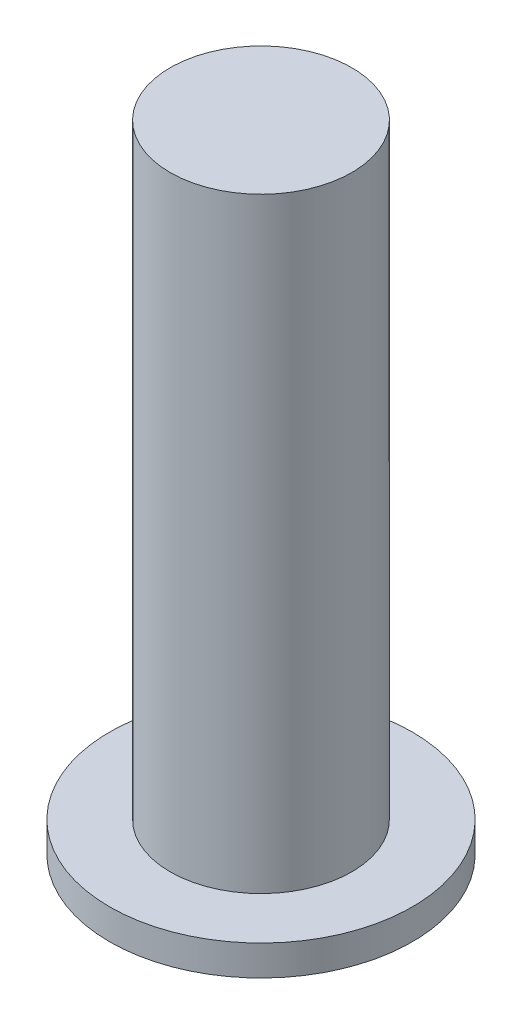
from build123d import *

# Parameters (mm, degrees)
SKETCH1_R           = 50
BOSS_EXTRUDE1_DEPTH = 10
SKETCH2_R           = 30
BOSS_EXTRUDE2_DEPTH = 200


with BuildPart() as part:
    # Sketch1 → Boss-Extrude1 (new body)
    with BuildSketch(Plane(origin=(0, 0, 0), x_dir=(1, 0, 0), z_dir=(0, 1, 0))):
        Circle(SKETCH1_R)
    extrude(amount=BOSS_EXTRUDE1_DEPTH)

    # Sketch2 → Boss-Extrude2 (add)
    with BuildSketch(Plane(origin=(0, 10, 0), x_dir=(1, 0, 0), z_dir=(0, 1, 0))):
        Circle(SKETCH2_R)
    extrude(amount=BOSS_EXTRUDE2_DEPTH)


solid = part.part
